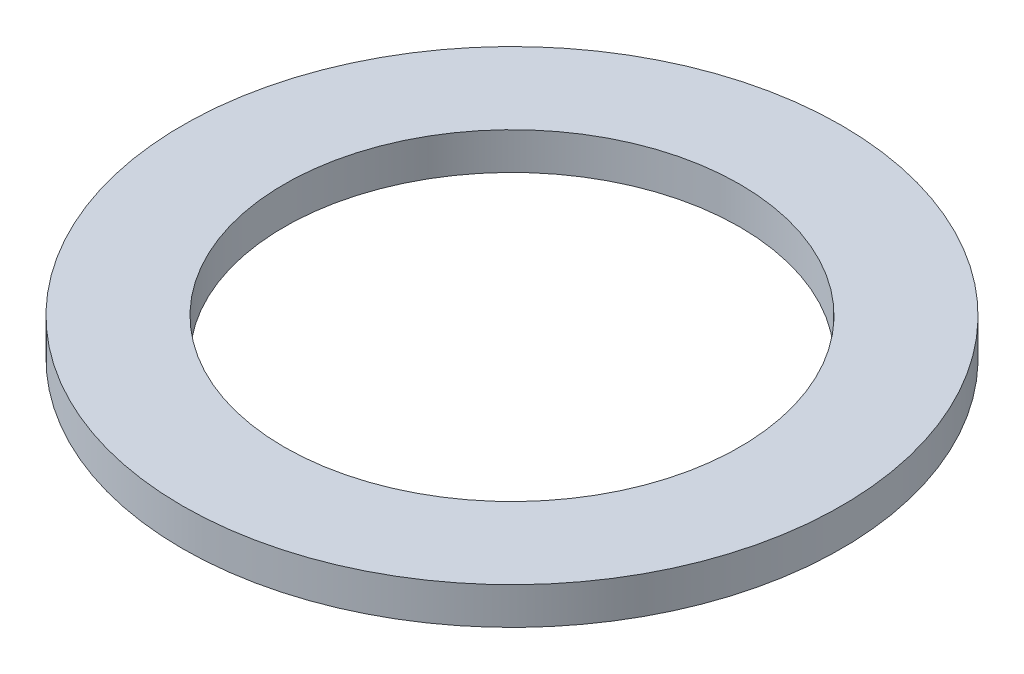
from build123d import *

# Parameters (mm, degrees)
SKETCH1_R           = 2.2606
BOSS_EXTRUDE1_DEPTH = 0.254
SKETCH5_R           = 1.5621
CUT_EXTRUDE1_DEPTH  = 1.254


with BuildPart() as part:
    # Sketch1 → Boss-Extrude1 (new body)
    with BuildSketch(Plane(origin=(0, 0, 0), x_dir=(1, 0, 0), z_dir=(0, 1, 0))):
        Circle(SKETCH1_R)
    extrude(amount=BOSS_EXTRUDE1_DEPTH)

    # Sketch5 → Cut-Extrude1 (cut, through all)
    with BuildSketch(Plane(origin=(0, 0.254, 0), x_dir=(-1, 0, 0), z_dir=(0, 1, 0))):
        Circle(SKETCH5_R)
    extrude(amount=-CUT_EXTRUDE1_DEPTH, mode=Mode.SUBTRACT)


solid = part.part
